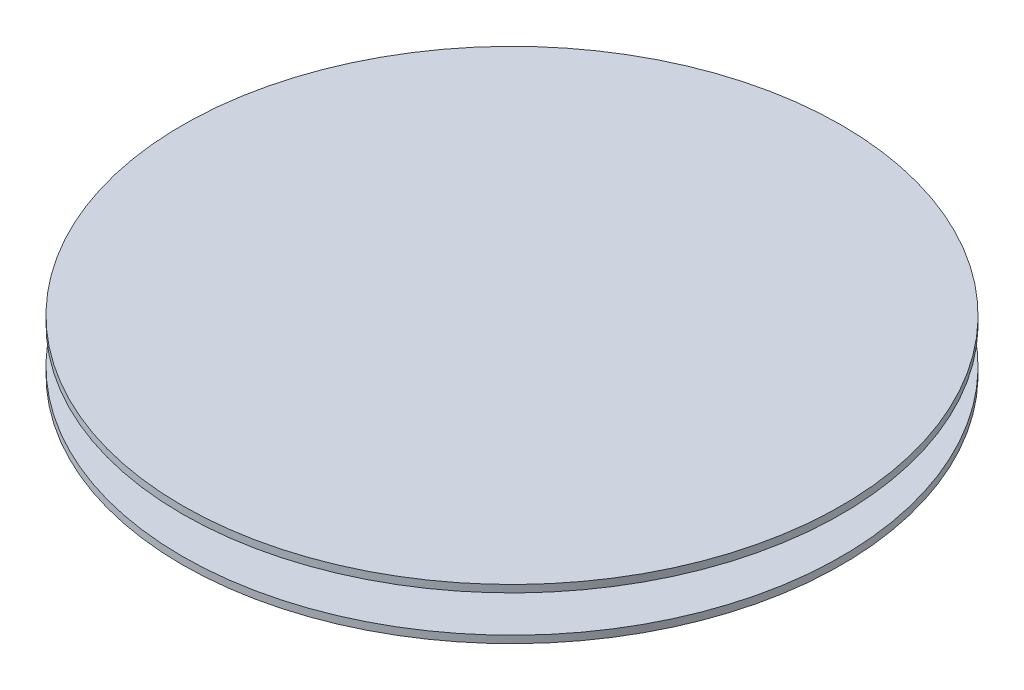
from build123d import *

# Parameters (mm, degrees)
SKETCH1_R           = 90
SKETCH1_R_2         = 75
BOSS_EXTRUDE1_DEPTH = 2
SKETCH2_R           = 75
BOSS_EXTRUDE2_DEPTH = 10
SKETCH4_R           = 90
BOSS_EXTRUDE3_DEPTH = 2
SKETCH5_R           = 70
CUT_EXTRUDE2_DEPTH  = 8


with BuildPart() as part:
    # Sketch1 → Boss-Extrude1 (new body)
    with BuildSketch(Plane(origin=(0, 0, 0), x_dir=(1, 0, 0), z_dir=(0, 1, 0))):
        Circle(SKETCH1_R)
        Circle(SKETCH1_R_2, mode=Mode.SUBTRACT)
    extrude(amount=BOSS_EXTRUDE1_DEPTH)


with BuildPart() as body_2:
    # Sketch2 → Boss-Extrude2 (new body)
    with BuildSketch(Plane(origin=(0, 2, 0), x_dir=(1, 0, 0), z_dir=(0, 1, 0))):
        Circle(SKETCH2_R)
    extrude(amount=BOSS_EXTRUDE2_DEPTH)

    # Sketch4 → Boss-Extrude3 (add)
    with BuildSketch(Plane(origin=(0, 12, 0), x_dir=(1, 0, 0), z_dir=(0, 1, 0))):
        Circle(SKETCH4_R)
    extrude(amount=BOSS_EXTRUDE3_DEPTH)

    # Sketch5 → Cut-Extrude2 (cut)
    with BuildSketch(Plane.XZ.offset(-2)):
        Circle(SKETCH5_R)
    extrude(amount=-CUT_EXTRUDE2_DEPTH, mode=Mode.SUBTRACT)


solid = Compound([part.part, body_2.part])
